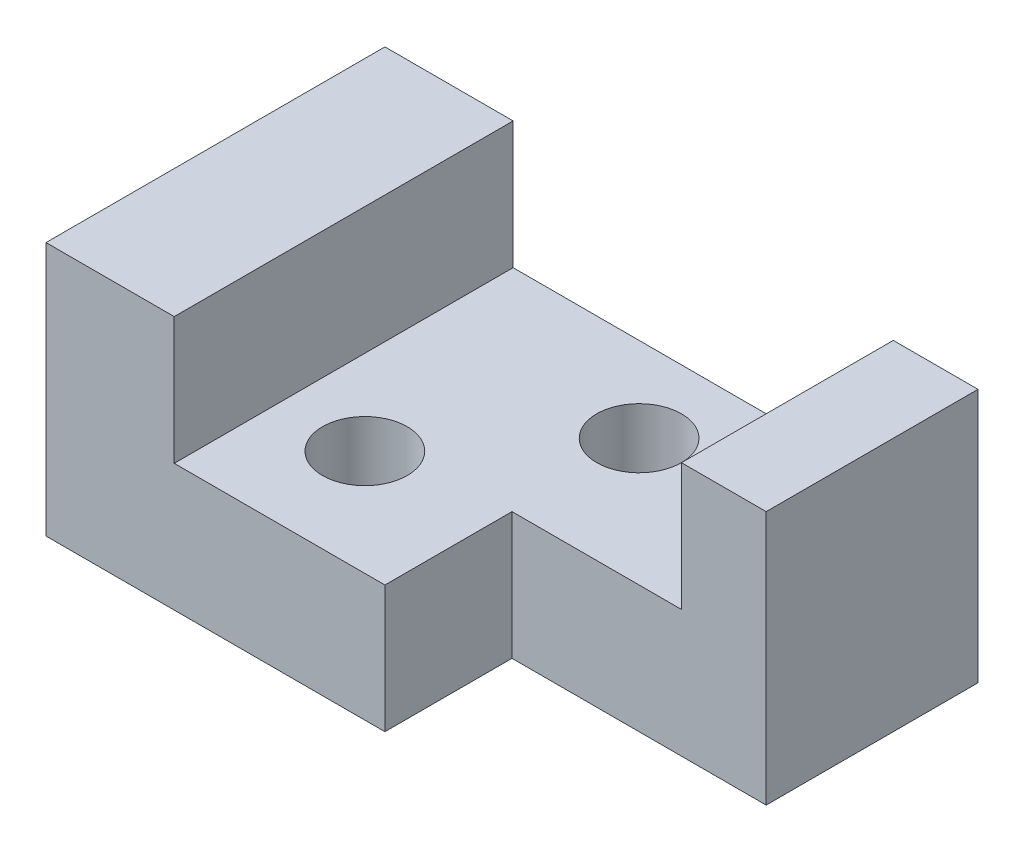
from build123d import *

# Parameters (mm, degrees)
SKETCH1_W           = 70
SKETCH1_H           = 40
BOSS_EXTRUDE1_DEPTH = 30
SKETCH2_W           = 30
SKETCH2_H           = 15
CUT_EXTRUDE1_DEPTH  = 31
SKETCH3_W           = 45
SKETCH3_H           = 15
CUT_EXTRUDE2_DEPTH  = 41
SKETCH4_W           = 15.133947596
SKETCH4_H           = 40
BOSS_EXTRUDE2_DEPTH = 15
SKETCH6_R           = 5
CUT_EXTRUDE3_DEPTH  = 16
SKETCH7_R           = 5
CUT_EXTRUDE4_DEPTH  = 16
SKETCH8_W           = 3.137431518
SKETCH8_H           = 25
CUT_EXTRUDE5_DEPTH  = 15


with BuildPart() as part:
    # Sketch1 → Boss-Extrude1 (new body)
    with BuildSketch(Plane(origin=(0, 0, 0), x_dir=(1, 0, 0), z_dir=(0, 1, 0))):
        with Locations((35, 20)):
            Rectangle(SKETCH1_W, SKETCH1_H)
    extrude(amount=BOSS_EXTRUDE1_DEPTH)

    # Sketch2 → Cut-Extrude1 (cut, through all)
    with BuildSketch(Plane(origin=(0, 30, 0), x_dir=(1, 0, 0), z_dir=(0, 1, 0))):
        with Locations((55, 7.5)):
            Rectangle(SKETCH2_W, SKETCH2_H)
    extrude(amount=-CUT_EXTRUDE1_DEPTH, mode=Mode.SUBTRACT)

    # Sketch3 → Cut-Extrude2 (cut, through all)
    with BuildSketch(Plane(origin=(0, 0, -40), x_dir=(-1, 0, 0), z_dir=(0, 0, -1))):
        with Locations((-34.362568482, 22.5)):
            Rectangle(SKETCH3_W, SKETCH3_H)
    extrude(amount=-CUT_EXTRUDE2_DEPTH, mode=Mode.SUBTRACT)

    # Sketch4 → Boss-Extrude2 (add)
    with BuildSketch(Plane(origin=(0, 30, 0), x_dir=(1, 0, 0), z_dir=(0, 1, 0))):
        with Locations((7.566973798, 20)):
            Rectangle(SKETCH4_W, SKETCH4_H)
    extrude(amount=-BOSS_EXTRUDE2_DEPTH)

    # Sketch6 → Cut-Extrude3 (cut, through all)
    with BuildSketch(Plane(origin=(0, 15, 0), x_dir=(1, 0, 0), z_dir=(0, 1, 0))):
        with Locations((40, 30)):
            Circle(SKETCH6_R)
    extrude(amount=-CUT_EXTRUDE3_DEPTH, mode=Mode.SUBTRACT)

    # Sketch7 → Cut-Extrude4 (cut, through all)
    with BuildSketch(Plane(origin=(0, 15, 0), x_dir=(1, 0, 0), z_dir=(0, 1, 0))):
        with Locations((25.133947596, 12.5)):
            Circle(SKETCH7_R)
    extrude(amount=-CUT_EXTRUDE4_DEPTH, mode=Mode.SUBTRACT)

    # Sketch8 → Cut-Extrude5 (cut)
    with BuildSketch(Plane(origin=(0, 30, 0), x_dir=(1, 0, 0), z_dir=(0, 1, 0))):
        with Locations((58.431284241, 27.5)):
            Rectangle(SKETCH8_W, SKETCH8_H)
    extrude(amount=-CUT_EXTRUDE5_DEPTH, mode=Mode.SUBTRACT)


solid = part.part
